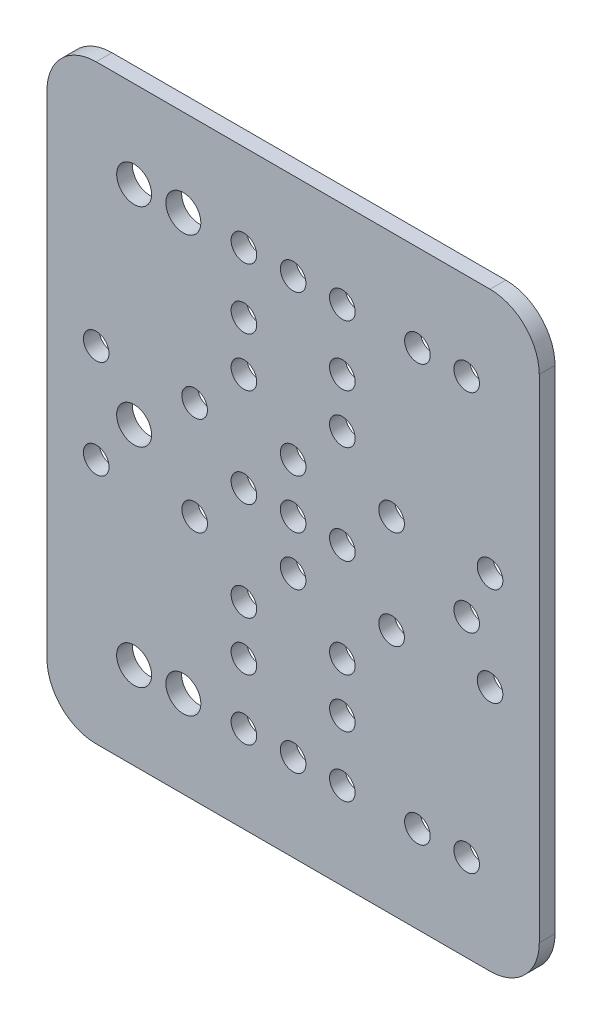
from build123d import *

# Parameters (mm, degrees)
SKETCH1_W           = 100
SKETCH1_H           = 120
SKETCH1_R           = 2.6
SKETCH1_R_2         = 3.55
BOSS_EXTRUDE1_DEPTH = 3.2
FILLET1_R           = 10


with BuildPart() as part:
    # Sketch1 → Boss-Extrude1 (new body)
    with BuildSketch(Plane.XY):
        Rectangle(SKETCH1_W, SKETCH1_H)
        Circle(SKETCH1_R, mode=Mode.SUBTRACT)
        with Locations((0, 10)):
            Circle(SKETCH1_R, mode=Mode.SUBTRACT)
        with Locations((0, 42.3)):
            Circle(SKETCH1_R, mode=Mode.SUBTRACT)
        with Locations((0, -10)):
            Circle(SKETCH1_R, mode=Mode.SUBTRACT)
        with Locations((10, -20)):
            Circle(SKETCH1_R, mode=Mode.SUBTRACT)
        with Locations((10, 0)):
            Circle(SKETCH1_R, mode=Mode.SUBTRACT)
        with Locations((-10, 0)):
            Circle(SKETCH1_R, mode=Mode.SUBTRACT)
        with Locations((-32.3, 0)):
            Circle(SKETCH1_R_2, mode=Mode.SUBTRACT)
        with Locations((35.25, 0)):
            Circle(SKETCH1_R, mode=Mode.SUBTRACT)
        with Locations((35.25, 42.3)):
            Circle(SKETCH1_R, mode=Mode.SUBTRACT)
        with Locations((10, -30)):
            Circle(SKETCH1_R, mode=Mode.SUBTRACT)
        with Locations((-10, -20)):
            Circle(SKETCH1_R, mode=Mode.SUBTRACT)
        with Locations((-32.3, 42.3)):
            Circle(SKETCH1_R_2, mode=Mode.SUBTRACT)
        with Locations((-22.3, 42.3)):
            Circle(SKETCH1_R_2, mode=Mode.SUBTRACT)
        with Locations((-10, -30)):
            Circle(SKETCH1_R, mode=Mode.SUBTRACT)
        with Locations((-40, 10)):
            Circle(SKETCH1_R, mode=Mode.SUBTRACT)
        with Locations((-20, 10)):
            Circle(SKETCH1_R, mode=Mode.SUBTRACT)
        with Locations((20, 10)):
            Circle(SKETCH1_R, mode=Mode.SUBTRACT)
        with Locations((40, 10)):
            Circle(SKETCH1_R, mode=Mode.SUBTRACT)
        with Locations((40, -10)):
            Circle(SKETCH1_R, mode=Mode.SUBTRACT)
        with Locations((20, -10)):
            Circle(SKETCH1_R, mode=Mode.SUBTRACT)
        with Locations((-20, -10)):
            Circle(SKETCH1_R, mode=Mode.SUBTRACT)
        with Locations((-40, -10)):
            Circle(SKETCH1_R, mode=Mode.SUBTRACT)
        with Locations((25.25, 42.3)):
            Circle(SKETCH1_R, mode=Mode.SUBTRACT)
        with Locations((10, 42.3)):
            Circle(SKETCH1_R, mode=Mode.SUBTRACT)
        with Locations((-10, 42.3)):
            Circle(SKETCH1_R, mode=Mode.SUBTRACT)
        with Locations((-10, 30)):
            Circle(SKETCH1_R, mode=Mode.SUBTRACT)
        with Locations((-10, 20)):
            Circle(SKETCH1_R, mode=Mode.SUBTRACT)
        with Locations((10, 30)):
            Circle(SKETCH1_R, mode=Mode.SUBTRACT)
        with Locations((10, 20)):
            Circle(SKETCH1_R, mode=Mode.SUBTRACT)
        with Locations((-10, -42.3)):
            Circle(SKETCH1_R, mode=Mode.SUBTRACT)
        with Locations((10, -42.3)):
            Circle(SKETCH1_R, mode=Mode.SUBTRACT)
        with Locations((25.25, -42.3)):
            Circle(SKETCH1_R, mode=Mode.SUBTRACT)
        with Locations((-22.3, -42.3)):
            Circle(SKETCH1_R_2, mode=Mode.SUBTRACT)
        with Locations((-32.3, -42.3)):
            Circle(SKETCH1_R_2, mode=Mode.SUBTRACT)
        with Locations((35.25, -42.3)):
            Circle(SKETCH1_R, mode=Mode.SUBTRACT)
        with Locations((0, -42.3)):
            Circle(SKETCH1_R, mode=Mode.SUBTRACT)
    extrude(amount=BOSS_EXTRUDE1_DEPTH)

    # Fillet1
    fillet1_edges = [part.edges().sort_by_distance(p)[0] for p in [
        (50, -60, 1.6),
        (-50, -60, 1.6),
        (-50, 60, 1.6),
        (50, 60, 1.6),
    ]]
    fillet(fillet1_edges, radius=FILLET1_R)


solid = part.part
